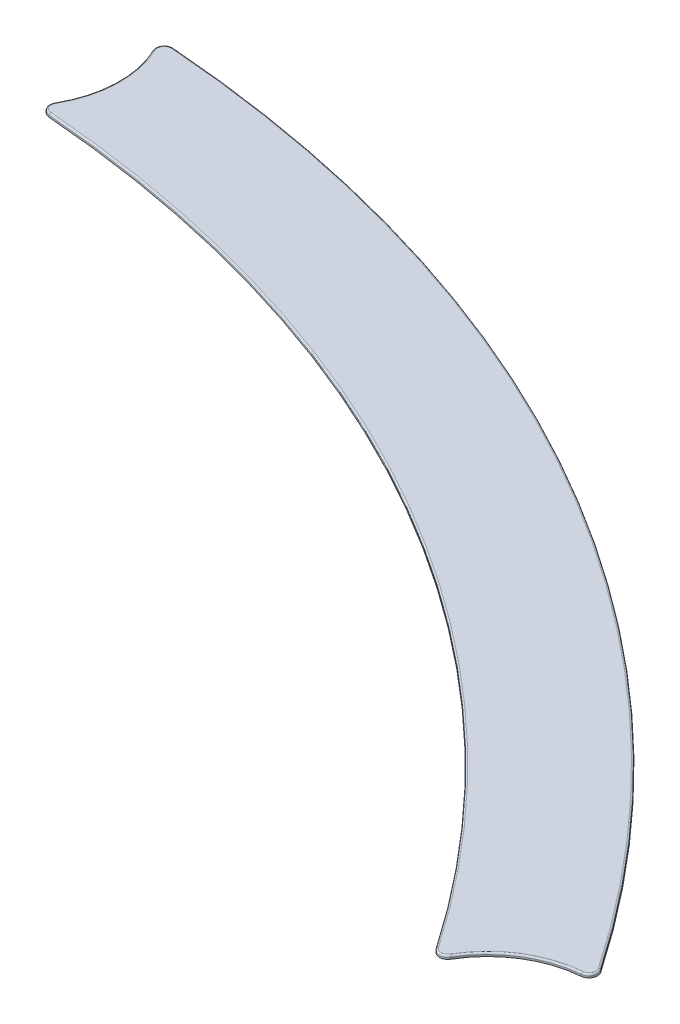
from build123d import *

# Parameters (mm, degrees)
BOSS_EXTRUDE1_DEPTH = 0.2
FILLET1_R           = 0.5
FILLET2_R           = 0.1


with BuildPart() as part:
    # Sketch1 → Boss-Extrude1 (new body)
    with BuildSketch(Plane(origin=(0, 0, 0), x_dir=(1, 0, 0), z_dir=(0, 1, 0))):
        with BuildLine():
            ThreePointArc((65.788496696, 43.736411632), (62.218735106, 42.846595528), (59.839367736, 40.040605253))
            ThreePointArc((59.839367736, 40.040605253), (36, 62.353829072), (4.756497464, 71.842715232))
            ThreePointArc((4.756497464, 71.842715232), (5.99687264, 75.306302957), (4.982595195, 78.842715232))
            ThreePointArc((4.982595195, 78.842715232), (39.5, 68.416006899), (65.788496696, 43.736411632))
        make_face()
    extrude(amount=BOSS_EXTRUDE1_DEPTH)

    # Fillet1
    fillet1_edges = [part.edges().sort_by_distance(p)[0] for p in [
        (65.788496696, 0.1, -43.736411632),
        (59.839367736, 0.1, -40.040605253),
        (4.756497464, 0.1, -71.842715232),
        (4.982595195, 0.1, -78.842715232),
    ]]
    fillet(fillet1_edges, radius=FILLET1_R)

    # Fillet2
    fillet2_edges = [part.edges().sort_by_distance(p)[0] for p in [
        (36, 0.2, -62.353829072),
        (5.995621864, 0.2, -75.270830923),
        (39.5, 0.2, -68.416006899),
        (62.188640811, 0.2, -42.827776307),
        (65.305737696, 0.2, -44.012960805),
        (59.791175202, 0.2, -40.530040556),
        (5.463473305, 0.2, -78.56290826),
        (5.204457137, 0.2, -72.045696925),
    ]]
    fillet(fillet2_edges, radius=FILLET2_R)


solid = part.part
